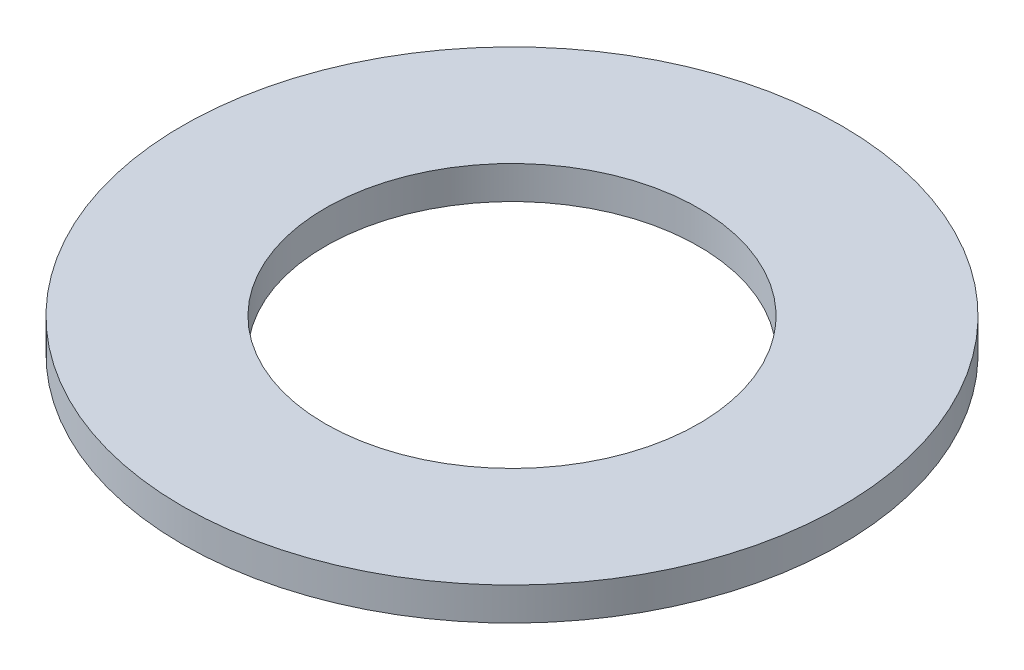
from build123d import *

# Parameters (mm, degrees)
SKETCH1_R           = 30
SKETCH1_R_2         = 17
BOSS_EXTRUDE1_DEPTH = 3


with BuildPart() as part:
    # Sketch1 → Boss-Extrude1 (new body)
    with BuildSketch(Plane(origin=(0, 0, 0), x_dir=(1, 0, 0), z_dir=(0, 1, 0))):
        Circle(SKETCH1_R)
        Circle(SKETCH1_R_2, mode=Mode.SUBTRACT)
    extrude(amount=BOSS_EXTRUDE1_DEPTH)


solid = part.part
